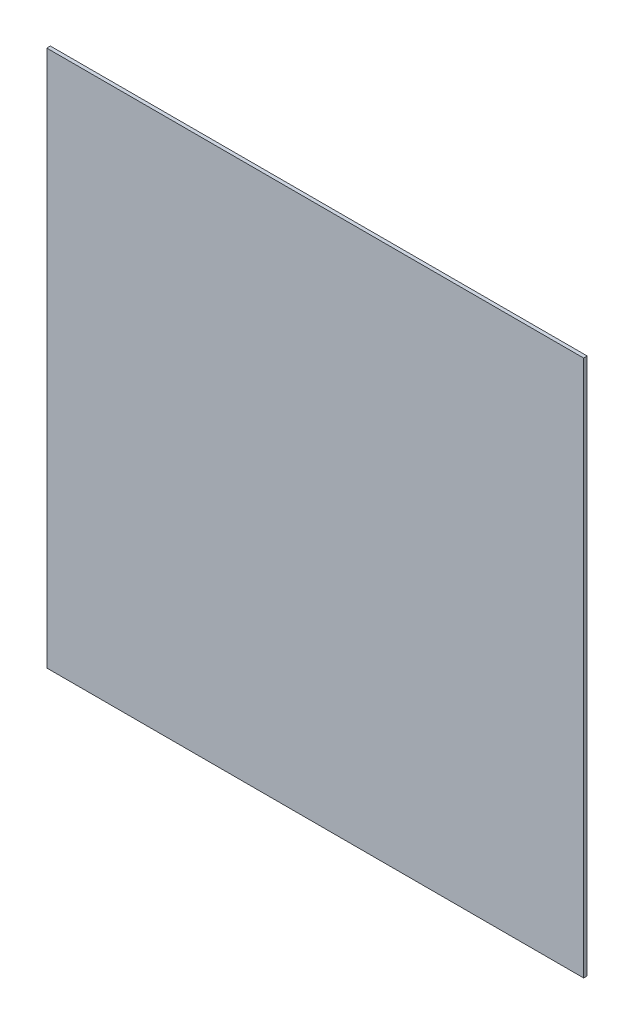
from build123d import *

# Parameters (mm, degrees)
SKETCH1_W           = 300
SKETCH1_H           = 300
BOSS_EXTRUDE1_DEPTH = 2


with BuildPart() as part:
    # Sketch1 → Boss-Extrude1 (new body)
    with BuildSketch(Plane.XY):
        Rectangle(SKETCH1_W, SKETCH1_H)
    extrude(amount=BOSS_EXTRUDE1_DEPTH)


solid = part.part
